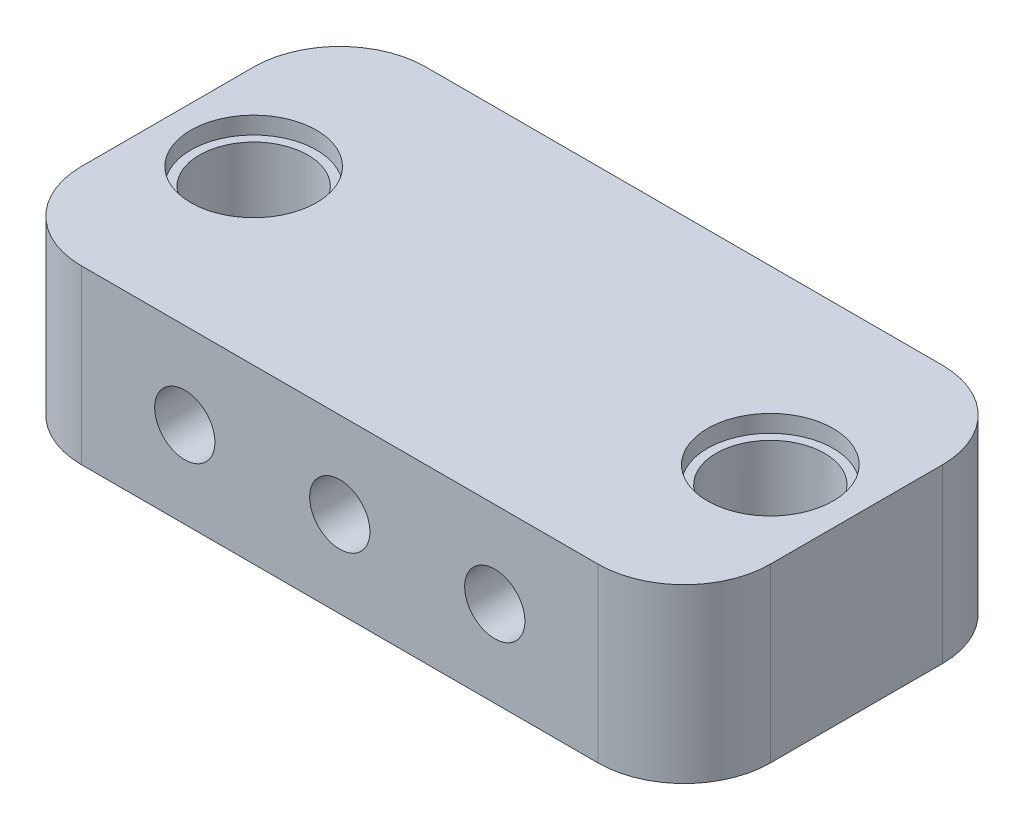
from build123d import *

# Parameters (mm, degrees)
ESQUISSE1_W                  = 40
ESQUISSE1_H                  = 10
BOSS_EXTRU_1_DEPTH           = 20
ESQUISSE2_R                  = 1.75
ENL_V_MAT_EXTRU_1_DEPTH      = 1
ENL_V_MAT_EXTRU_1_DEPTH_BACK = 21
ESQUISSE3_R                  = 3.15
ENL_V_MAT_EXTRU_2_DEPTH      = 1
ENL_V_MAT_EXTRU_2_DEPTH_BACK = 11
ESQUISSE4_R                  = 3.65
ENL_V_MAT_EXTRU_3_DEPTH      = 1
CONG_1_R                     = 5


with BuildPart() as part:
    # Esquisse1 → Boss.-Extru.1 (new body)
    with BuildSketch(Plane.XY):
        with Locations((20, 5)):
            Rectangle(ESQUISSE1_W, ESQUISSE1_H)
    extrude(amount=BOSS_EXTRU_1_DEPTH)

    # Esquisse2 → Enlèv. mat.-Extru.1 (cut, two sides)
    with BuildSketch(Plane.XY.offset(20)) as enl_v_mat_extru_1_sk:
        with Locations((20, 5)):
            Circle(ESQUISSE2_R)
        with Locations((11, 5)):
            Circle(ESQUISSE2_R)
        with Locations((29, 5)):
            Circle(ESQUISSE2_R)
    extrude(amount=ENL_V_MAT_EXTRU_1_DEPTH, mode=Mode.SUBTRACT)
    extrude(enl_v_mat_extru_1_sk.sketch, amount=-ENL_V_MAT_EXTRU_1_DEPTH_BACK, mode=Mode.SUBTRACT)

    # Esquisse3 → Enlèv. mat.-Extru.2 (cut, two sides)
    with BuildSketch(Plane(origin=(0, 10, 0), x_dir=(1, 0, 0), z_dir=(0, 1, 0))) as enl_v_mat_extru_2_sk:
        with Locations((5, -10)):
            Circle(ESQUISSE3_R)
        with Locations((35, -10)):
            Circle(ESQUISSE3_R)
    extrude(amount=ENL_V_MAT_EXTRU_2_DEPTH, mode=Mode.SUBTRACT)
    extrude(enl_v_mat_extru_2_sk.sketch, amount=-ENL_V_MAT_EXTRU_2_DEPTH_BACK, mode=Mode.SUBTRACT)

    # Esquisse4 → Enlèv. mat.-Extru.3 (cut)
    with BuildSketch(Plane(origin=(0, 10, 0), x_dir=(1, 0, 0), z_dir=(0, 1, 0))):
        with Locations((5, -10)):
            Circle(ESQUISSE4_R)
        with Locations((35, -10)):
            Circle(ESQUISSE4_R)
    extrude(amount=-ENL_V_MAT_EXTRU_3_DEPTH, mode=Mode.SUBTRACT)

    # Congé1
    cong_1_edges = [part.edges().sort_by_distance(p)[0] for p in [
        (40, 5, 20),
        (0, 5, 20),
        (40, 5, 0),
        (0, 5, 0),
    ]]
    fillet(cong_1_edges, radius=CONG_1_R)


solid = part.part
